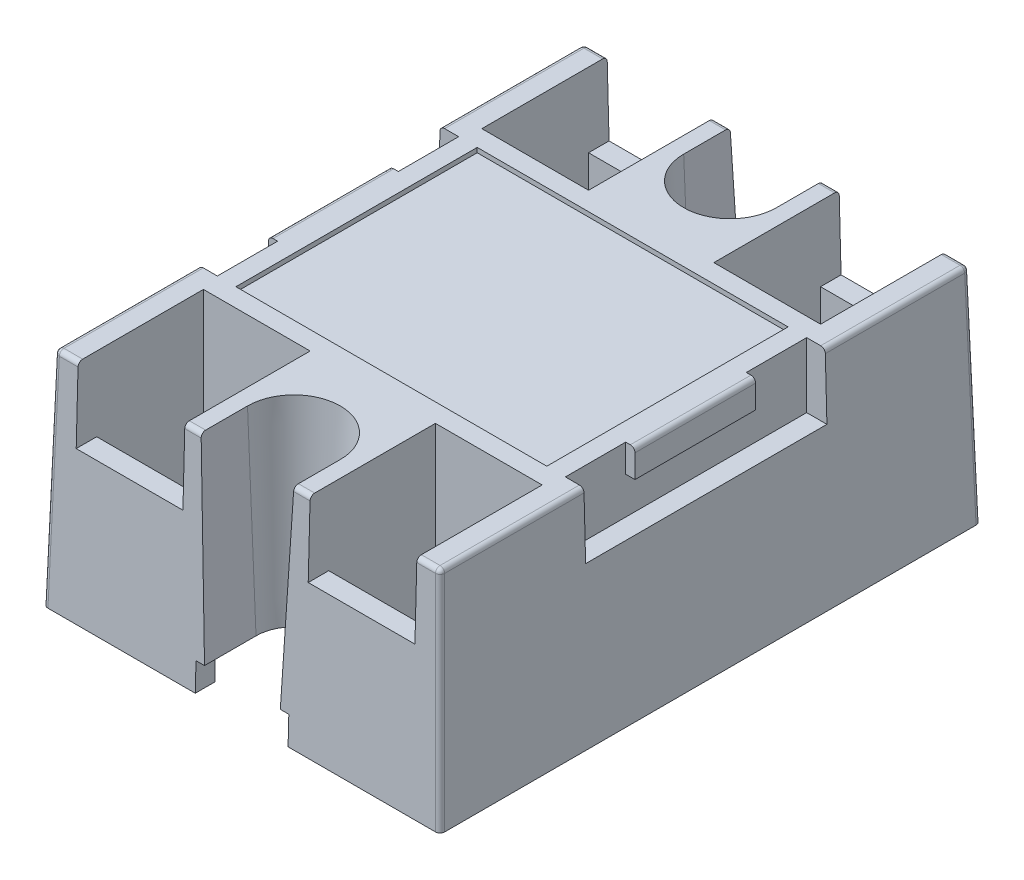
from build123d import *

# Parameters (mm, degrees)
SKETCH1_W           = 41.5
SKETCH1_H           = 57
BOSS_EXTRUDE1_DEPTH = 24
CUT_EXTRUDE1_DEPTH  = 21
CUT_EXTRUDE1_TAPER  = 2.5
SKETCH3_W           = 11.5
SKETCH3_H           = 13.5
CUT_EXTRUDE2_DEPTH  = 8
SKETCH4_W           = 11.5
SKETCH4_H           = 11.5
CUT_EXTRUDE3_DEPTH  = 17.0000001
SKETCH5_W           = 26
SKETCH5_H           = 7
CUT_EXTRUDE4_DEPTH  = 2
SKETCH6_W           = 13
SKETCH6_H           = 3
BOSS_EXTRUDE2_DEPTH = 1
SKETCH7_W           = 33.5
SKETCH7_H           = 26
CUT_EXTRUDE5_DEPTH  = 0.5
SKETCH8_W           = 38.5
SKETCH8_H           = 54
CUT_EXTRUDE6_DEPTH  = 3
SKETCH9_W           = 10
SKETCH9_H           = 3
CUT_EXTRUDE7_DEPTH  = 58.0000001
DRAFT1_ANGLE        = 1.5
FILLET1_R           = 0.5
SKETCH10_R          = 1.25
BOSS_EXTRUDE3_DEPTH = 2.5
CHAMFER1_SIZE       = 0.25


with BuildPart() as part:
    # Sketch1 → Boss-Extrude1 (new body)
    with BuildSketch(Plane(origin=(0, 0, 0), x_dir=(1, 0, 0), z_dir=(0, 1, 0))):
        Rectangle(SKETCH1_W, SKETCH1_H)
    extrude(amount=BOSS_EXTRUDE1_DEPTH)

    # Sketch2 → Cut-Extrude1 (cut)
    with BuildSketch(Plane(origin=(0, 24, 0), x_dir=(1, 0, 0), z_dir=(0, 1, 0))):
        with BuildLine():
            Line((-5, -23.5), (-5, -30.5))
            Line((-5, -30.5), (5, -30.5))
            Line((5, -30.5), (5, -23.5))
            ThreePointArc((5, -23.5), (0, -18.5), (-5, -23.5))
        make_face()
    cut_extrude1 = extrude(amount=-CUT_EXTRUDE1_DEPTH, taper=CUT_EXTRUDE1_TAPER, mode=Mode.SUBTRACT)

    # Sketch3 → Cut-Extrude2 (cut)
    with BuildSketch(Plane(origin=(0, 24, 0), x_dir=(1, 0, 0), z_dir=(0, 1, 0))):
        with Locations((-12.5, -21.75)):
            Rectangle(SKETCH3_W, SKETCH3_H)
        with Locations((12.5, -21.75)):
            Rectangle(SKETCH3_W, SKETCH3_H)
    cut_extrude2 = extrude(amount=-CUT_EXTRUDE2_DEPTH, mode=Mode.SUBTRACT)

    # Sketch4 → Cut-Extrude3 (cut, through all)
    with BuildSketch(Plane(origin=(0, 16, 0), x_dir=(1, 0, 0), z_dir=(0, 1, 0))):
        with Locations((-12.5, -20.75)):
            Rectangle(SKETCH4_W, SKETCH4_H)
        with Locations((12.5, -20.75)):
            Rectangle(SKETCH4_W, SKETCH4_H)
    cut_extrude3 = extrude(amount=-CUT_EXTRUDE3_DEPTH, mode=Mode.SUBTRACT)

    # Mirror1: Cut-Extrude1, Cut-Extrude2, Cut-Extrude3 across plane
    add(cut_extrude1.mirror(Plane.XY), mode=Mode.SUBTRACT)
    add(cut_extrude2.mirror(Plane.XY), mode=Mode.SUBTRACT)
    add(cut_extrude3.mirror(Plane.XY), mode=Mode.SUBTRACT)

    # Sketch5 → Cut-Extrude4 (cut)
    with BuildSketch(Plane.ZY.offset(20.75)):
        with Locations((0, 20.5)):
            Rectangle(SKETCH5_W, SKETCH5_H)
    cut_extrude4 = extrude(amount=-CUT_EXTRUDE4_DEPTH, mode=Mode.SUBTRACT)

    # Sketch6 → Boss-Extrude2 (add)
    with BuildSketch(Plane.ZY.offset(18.75)):
        with Locations((0, 22.5)):
            Rectangle(SKETCH6_W, SKETCH6_H)
    boss_extrude2 = extrude(amount=BOSS_EXTRUDE2_DEPTH)

    # Mirror2: Cut-Extrude4, Boss-Extrude2 across plane
    add(cut_extrude4.mirror(Plane(origin=(0, 0, 0), x_dir=(0, 0, 1), z_dir=(1, 0, 0))), mode=Mode.SUBTRACT)
    add(boss_extrude2.mirror(Plane(origin=(0, 0, 0), x_dir=(0, 0, 1), z_dir=(1, 0, 0))))

    # Sketch7 → Cut-Extrude5 (cut)
    with BuildSketch(Plane(origin=(0, 24, 0), x_dir=(1, 0, 0), z_dir=(0, 1, 0))):
        Rectangle(SKETCH7_W, SKETCH7_H)
    extrude(amount=-CUT_EXTRUDE5_DEPTH, mode=Mode.SUBTRACT)

    # Sketch8 → Cut-Extrude6 (cut)
    with BuildSketch(Plane.XZ):
        Rectangle(SKETCH8_W, SKETCH8_H)
    extrude(amount=-CUT_EXTRUDE6_DEPTH, mode=Mode.SUBTRACT)

    # Sketch9 → Cut-Extrude7 (cut, through all)
    with BuildSketch(Plane(origin=(0, 0, -28.5), x_dir=(-1, 0, 0), z_dir=(0, 0, -1))):
        with Locations((0, 1.5)):
            Rectangle(SKETCH9_W, SKETCH9_H)
    extrude(amount=-CUT_EXTRUDE7_DEPTH, mode=Mode.SUBTRACT)

    # Draft1
    draft1_faces = [part.faces().sort_by_distance(p)[0] for p in [
        (-12.725295126, 9.445247328, -28.5),
        (12.725295126, 9.445247328, -28.5),
        (-20.75, 10.695615514, 0),
        (-12.725295126, 9.445247328, 28.5),
        (12.725295126, 9.445247328, 28.5),
        (20.75, 10.695615514, 0),
    ]]
    draft(draft1_faces, Plane.ZX.offset(24), DRAFT1_ANGLE)

    # Fillet1
    fillet1_edges = [part.edges().sort_by_distance(p)[0] for p in [
        (-20.75, 24, -20.75),
        (-19.5, 24, -28.5),
        (5.875, 24, -28.5),
        (-19.5, 24, 28.5),
        (5.875, 24, 28.5),
        (-20.75, 24, 20.75),
        (-19.75, 24, 0),
        (20.75, 24, -20.75),
        (19.75, 24, 0),
        (-5.875, 24, 28.5),
        (20.75, 24, 20.75),
        (19.5, 24, 28.5),
        (19.5, 24, -28.5),
        (21.064231059, 12, 28.814231059),
        (-21.064231059, 12, 28.814231059),
        (-21.064231059, 12, -28.814231059),
        (21.064231059, 12, -28.814231059),
        (-5.875, 24, -28.5),
    ]]
    fillet(fillet1_edges, radius=FILLET1_R)

    # Sketch10 → Boss-Extrude3 (add)
    with BuildSketch(Plane.XZ.offset(-3)):
        with Locations((7, 7.25)):
            Circle(SKETCH10_R)
    extrude(amount=BOSS_EXTRUDE3_DEPTH)

    # Chamfer1
    chamfer1_edges = [part.edges().sort_by_distance(p)[0] for p in [
        (5.75, 0.5, 7.25),
    ]]
    chamfer(chamfer1_edges, length=CHAMFER1_SIZE)


solid = part.part
